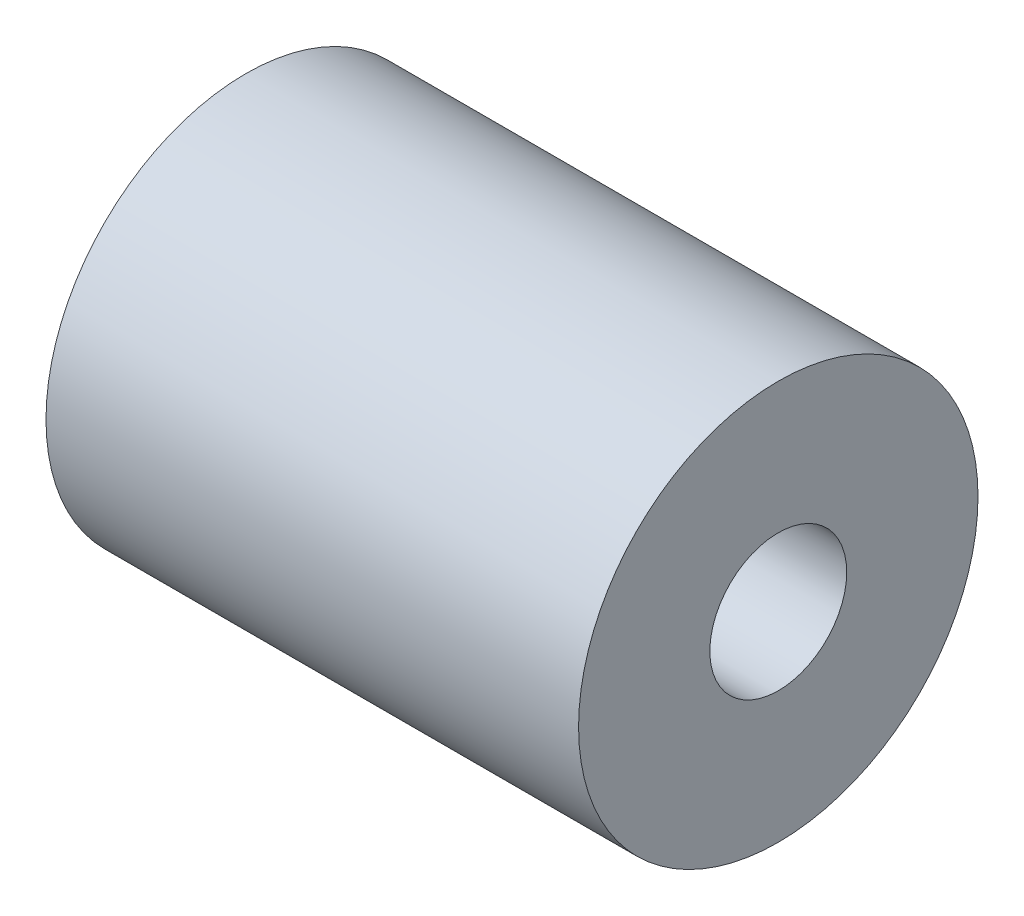
from build123d import *

# Parameters (mm, degrees)
SKETCH1_R           = 9.525
SKETCH1_R_2         = 3.2639
BOSS_EXTRUDE1_DEPTH = 25.4


with BuildPart() as part:
    # Sketch1 → Boss-Extrude1 (new body)
    with BuildSketch(Plane(origin=(0, 0, 0), x_dir=(0, 0, -1), z_dir=(1, 0, 0))):
        Circle(SKETCH1_R)
        Circle(SKETCH1_R_2, mode=Mode.SUBTRACT)
    extrude(amount=BOSS_EXTRUDE1_DEPTH)


solid = part.part
